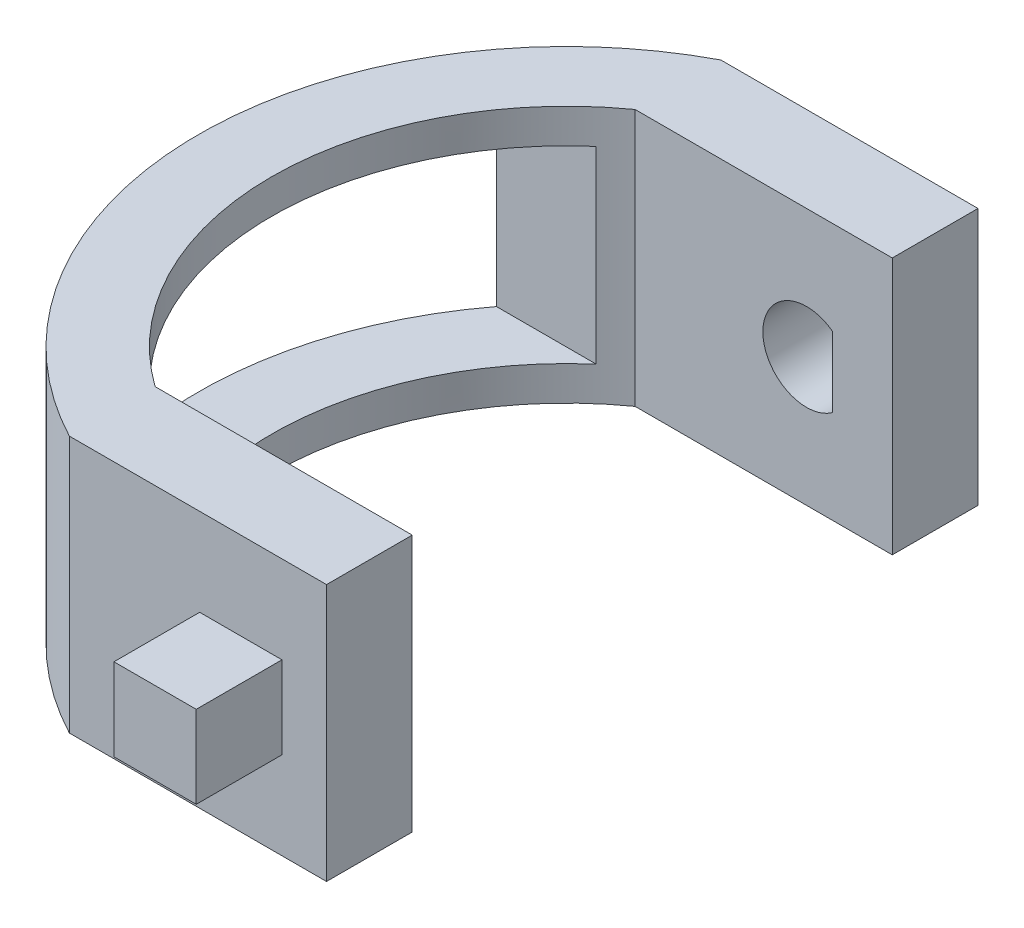
from build123d import *

# Parameters (mm, degrees)
SKIZZE7_W                            = 4.8
SKIZZE7_H                            = 4.8
AUFSATZ_LINEAR_AUSTRAGEN3_DEPTH      = 5
SKIZZE7_3_W                          = 15
SKIZZE7_3_H                          = 15
SKIZZE7_3_W_2                        = 4.8
SKIZZE7_3_H_2                        = 4.8
AUFSATZ_LINEAR_AUSTRAGEN4_DEPTH      = 5
AUFSATZ_LINEAR_START                 = -38
SKIZZE7_4_W                          = 15
SKIZZE7_4_H                          = 15
AUFSATZ_LINEAR_AUSTRAGEN5_DEPTH      = 5
AUFSATZ_LINEAR_AUSTRAGEN6_DEPTH      = 15
SCHNITT_LINEAR_AUSTRAGEN6_REACH      = 50.07
SCHNITT_LINEAR_AUSTRAGEN7_REACH      = 49.357
SCHNITT_LINEAR_AUSTRAGEN7_END_RADIUS = 21.470910554
SKIZZE12_W                           = 26
SKIZZE12_H                           = 11


with BuildPart() as part:
    # Skizze7 (on Front Plane) → Aufsatz-Linear austragen3 (new body)
    with BuildSketch(Plane.XY):
        with Locations((2.4, -2.4)):
            Rectangle(SKIZZE7_W, SKIZZE7_H)
    extrude(amount=AUFSATZ_LINEAR_AUSTRAGEN3_DEPTH)

    # Skizze7_3 (on Front Plane) → Aufsatz-Linear austragen4 (add)
    with BuildSketch(Plane.XY):
        with Locations((-0.1, -2.4)):
            Rectangle(SKIZZE7_3_W, SKIZZE7_3_H)
        with Locations((2.4, -2.4)):
            Rectangle(SKIZZE7_3_W_2, SKIZZE7_3_H_2, mode=Mode.SUBTRACT)
        with Locations((2.4, -2.4)):
            Rectangle(SKIZZE7_3_W_2, SKIZZE7_3_H_2)
    extrude(amount=-AUFSATZ_LINEAR_AUSTRAGEN4_DEPTH)



with BuildPart() as body_2:
    # Skizze7_4 → Aufsatz-Linear austragen5 (new body)
    with BuildSketch(Plane.XY.offset(AUFSATZ_LINEAR_START)):
        with Locations((-0.1, -2.4)):
            Rectangle(SKIZZE7_4_W, SKIZZE7_4_H)
    extrude(amount=AUFSATZ_LINEAR_AUSTRAGEN5_DEPTH)


with BuildPart() as part_1:
    add(part.part)

    add(body_2.part)  # Aufsatz-Linear austragen6 merges body 2
    # Skizze9 → Aufsatz-Linear austragen6 (add)
    with BuildSketch(Plane(origin=(0, 5.1, 0), x_dir=(1, 0, 0), z_dir=(0, 1, 0))):
        with BuildLine():
            Line((-7.6, 0), (-7.6, 5))
            ThreePointArc((-7.6, 5), (-14.804650534, 19), (-7.6, 33))
            Line((-7.6, 33), (-7.6, 38))
            ThreePointArc((-7.6, 38), (-19.070910554, 19), (-7.6, 0))
        make_face()
    extrude(amount=-AUFSATZ_LINEAR_AUSTRAGEN6_DEPTH)

    # Skizze11 → Schnitt-Linear austragen6 (cut, up to next)
    with BuildSketch(Plane(origin=(0, 0, -38), x_dir=(-1, 0, 0), z_dir=(0, 0, -1)), mode=Mode.PRIVATE) as schnitt_linear_austragen6_sk1:
        with BuildLine():
            Line((-3.9, -0.337840937), (-3.9, -4.462159063))
            ThreePointArc((-3.9, -4.462159063), (-1.242956353, -4.672388611), (0.15, -2.4))
            ThreePointArc((0.15, -2.4), (-1.242956353, -0.127611389), (-3.9, -0.337840937))
        make_face()
    schnitt_linear_austragen6_tool1 = extrude(schnitt_linear_austragen6_sk1.sketch, amount=-SCHNITT_LINEAR_AUSTRAGEN6_REACH, mode=Mode.PRIVATE) & part_1.part
    add(schnitt_linear_austragen6_tool1.solids().sort_by_distance((2.063945, -2.4, -38))[0], mode=Mode.SUBTRACT)

    # Schnitt-Linear austragen7: up to this cylinder (the profile starts inside it)
    schnitt_linear_austragen7_end = Plane(origin=(2.4, -2.4, -19), z_dir=(0, 1, 0)) * Cylinder(SCHNITT_LINEAR_AUSTRAGEN7_END_RADIUS, 142.655821107, mode=Mode.PRIVATE)
    # Skizze12 → Schnitt-Linear austragen7 (cut, up to the surface)
    with BuildSketch(Plane(origin=(7.4, 0, 0), x_dir=(0, 0, -1), z_dir=(1, 0, 0)), mode=Mode.PRIVATE) as schnitt_linear_austragen7_sk1:
        with Locations((19, -2.4)):
            Rectangle(SKIZZE12_W, SKIZZE12_H)
    schnitt_linear_austragen7_tool1 = extrude(schnitt_linear_austragen7_sk1.sketch, amount=-SCHNITT_LINEAR_AUSTRAGEN7_REACH, mode=Mode.PRIVATE) & schnitt_linear_austragen7_end
    add(schnitt_linear_austragen7_tool1.solids().sort_by_distance((7.4, -2.4, -19))[0], mode=Mode.SUBTRACT)


solid = part_1.part
